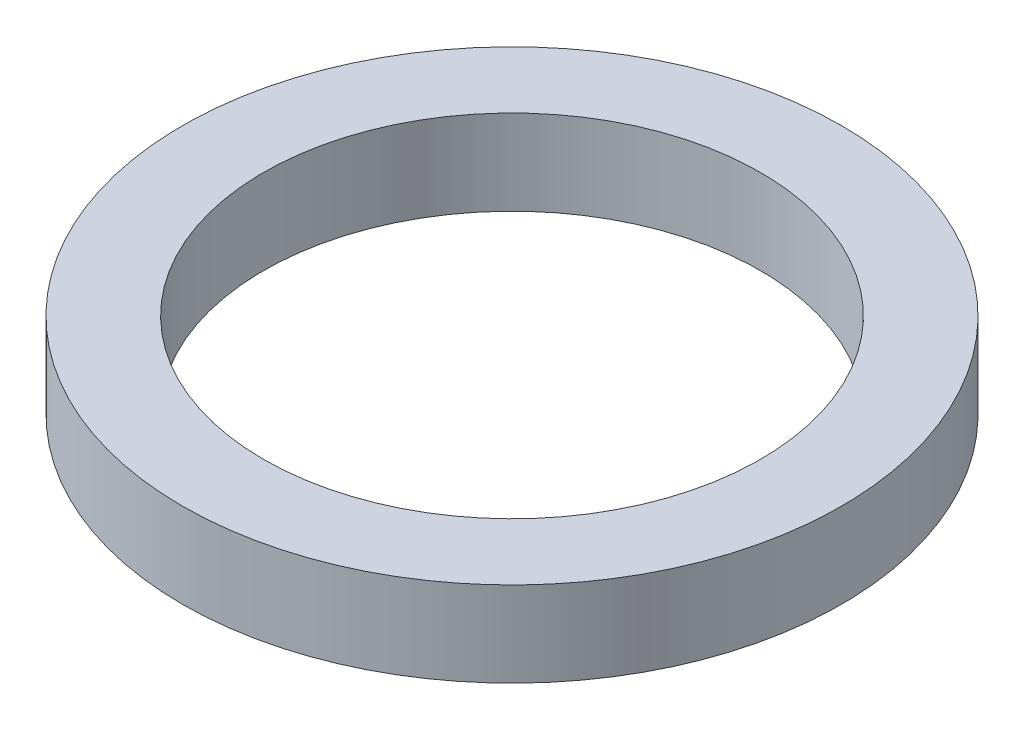
from build123d import *

# Parameters (mm, degrees)
SKETCH1_R           = 3.1496
SKETCH1_R_2         = 2.3749
BOSS_EXTRUDE1_DEPTH = 0.8128


with BuildPart() as part:
    # Sketch1 → Boss-Extrude1 (new body)
    with BuildSketch(Plane(origin=(0, 0, 0), x_dir=(1, 0, 0), z_dir=(0, 1, 0))):
        Circle(SKETCH1_R)
        Circle(SKETCH1_R_2, mode=Mode.SUBTRACT)
    extrude(amount=BOSS_EXTRUDE1_DEPTH)


solid = part.part
